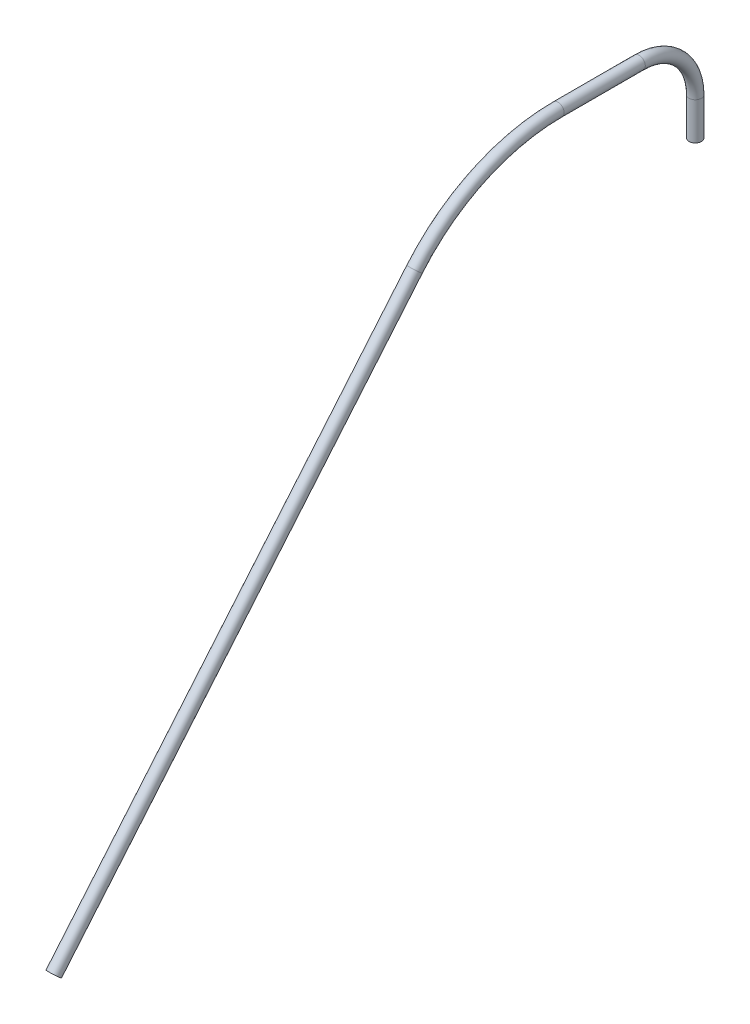
from build123d import *

# Parameters (mm, degrees)
SKETCH1_R = 3.3


with BuildPart() as part:
    # Sweep1: sweep along a path in Sketch2
    with BuildLine(Plane(origin=(0, 0, 0), x_dir=(0, 0, -1), z_dir=(1, 0, 0))) as sweep1_path:
        Line((0, 0), (0, 20))
        ThreePointArc((0, 20), (-8.786796564, 41.213203436), (-30, 50))
        Line((-30, 50), (-73.395555688, 50))
        ThreePointArc((-73.395555688, 50), (-115.657381862, 40.630778704), (-150, 14.278760969))
        Line((-150, 14.278760969), (-342.836282906, -215.534571967))
    # Sketch1 → Sweep1 (sweep)
    with BuildSketch(Plane(origin=(0, 0, 0), x_dir=(1, 0, 0), z_dir=(0, 1, 0))):
        Circle(SKETCH1_R)
    sweep(path=sweep1_path.line)


solid = part.part
